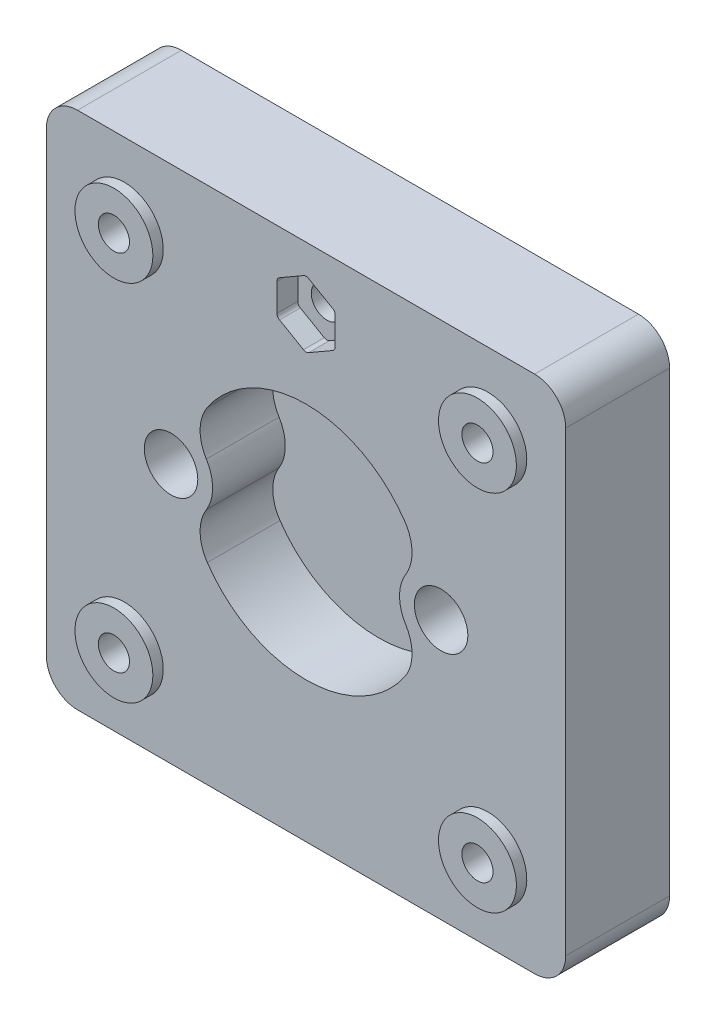
from build123d import *

# Parameters (mm, degrees)
SKETCH1_W               = 50
SKETCH1_H               = 50
BODY_DEPTH              = 10
SKETCH2_R               = 11.5
CUT_VIEW_DEPTH          = 7
FILLETBODY_R            = 3
SKETCH3_R               = 3.75
BOLT_EXTRUDE_DEPTH      = 1
SKETCH4_R               = 1.5
BOLT_DEPTH              = 10
BOLT_DEPTH_BACK         = 16
HEX_2_DEPTH             = 2
SKETCH19_R              = 1.5
HEX_BOLT_DEPTH          = 3
SKETCH6_R               = 4
FIELD1_DEPTH            = 7
FIELD2_R                = 4
SKETCH7_R               = 2.575
PORTS1_DEPTH            = 12
SKETCH10_R              = 1.575
PORTS2_DEPTH            = 12
PORTS2_DEPTH_BACK       = 32
SKETCH11_R              = 20
SKETCH11_R_2            = 15
SEAL1_DEPTH             = 0.5
FLOWFIELD_DEPTH         = 1.5
FLOWFIELD_CHANNEL_DEPTH = 1.5
BODY_MOVE_COPY1_ANGLE   = 90
BODY_MOVE_COPY2_ANGLE   = 180
SKETCH20_R              = 2.575
CUT_EXTRUDE1_DEPTH      = 17
FILLET1_R               = 0.5


with BuildPart() as part:
    # Sketch1 → Body (new body)
    with BuildSketch(Plane(origin=(0, 0, 0), x_dir=(1, 0, 0), z_dir=(0, 1, 0))):
        Rectangle(SKETCH1_W, SKETCH1_H)
    extrude(amount=BODY_DEPTH)

    # Sketch2 → Cut view (cut)
    with BuildSketch(Plane(origin=(0, 10, 0), x_dir=(1, 0, 0), z_dir=(0, 1, 0))):
        Circle(SKETCH2_R)
    extrude(amount=-CUT_VIEW_DEPTH, mode=Mode.SUBTRACT)

    # FilletBody
    filletbody_edges = [part.edges().sort_by_distance(p)[0] for p in [
        (-25, 5, -25),
        (25, 5, -25),
        (25, 5, 25),
        (-25, 5, 25),
    ]]
    fillet(filletbody_edges, radius=FILLETBODY_R)

    # Sketch3 → Bolt extrude (add)
    with BuildSketch(Plane(origin=(0, 10, 0), x_dir=(1, 0, 0), z_dir=(0, 1, 0))):
        with Locations((-17.5, 17.5)):
            Circle(SKETCH3_R)
        with Locations((17.5, 17.5)):
            Circle(SKETCH3_R)
        with Locations((17.5, -17.5)):
            Circle(SKETCH3_R)
        with Locations((-17.5, -17.5)):
            Circle(SKETCH3_R)
    extrude(amount=BOLT_EXTRUDE_DEPTH)

    # Sketch4 → Bolt (cut, two sides)
    with BuildSketch(Plane(origin=(0, 11, 0), x_dir=(1, 0, 0), z_dir=(0, 1, 0))) as bolt_sk:
        with Locations((-17.5, 17.5)):
            Circle(SKETCH4_R)
        with Locations((17.5, 17.5)):
            Circle(SKETCH4_R)
        with Locations((17.5, -17.5)):
            Circle(SKETCH4_R)
        with Locations((-17.5, -17.5)):
            Circle(SKETCH4_R)
    extrude(amount=BOLT_DEPTH, mode=Mode.SUBTRACT)
    extrude(bolt_sk.sketch, amount=-BOLT_DEPTH_BACK, mode=Mode.SUBTRACT)

    # Sketch5 → Hex 2 (cut)
    with BuildSketch(Plane(origin=(0, 10, 0), x_dir=(1, 0, 0), z_dir=(0, 1, 0))):
        Polygon((0, 22.233161507), (-2.8, 20.616580754), (-2.8, 17.383419246), (0, 15.766838493), (2.8, 17.383419246), (2.8, 20.616580754), align=None)
    extrude(amount=-HEX_2_DEPTH, mode=Mode.SUBTRACT)

    # Sketch19 → Hex_bolt (cut)
    with BuildSketch(Plane(origin=(0, 8, 0), x_dir=(1, 0, 0), z_dir=(0, 1, 0))):
        with Locations((0, 19)):
            Circle(SKETCH19_R)
    extrude(amount=-HEX_BOLT_DEPTH, mode=Mode.SUBTRACT)

    # Sketch6 → Field1 (add)
    with BuildSketch(Plane(origin=(0, 10, 0), x_dir=(1, 0, 0), z_dir=(0, 1, 0))):
        with Locations((-13, 0)):
            Circle(SKETCH6_R)
        with Locations((13, 0)):
            Circle(SKETCH6_R)
    extrude(amount=-FIELD1_DEPTH)

    # Field2
    field2_edges = [part.edges().sort_by_distance(p)[0] for p in [
        (-10.971153846, 6.5, 3.447286365),
        (-10.971153846, 6.5, -3.447286365),
        (10.971153846, 6.5, -3.447286365),
        (10.971153846, 6.5, 3.447286365),
    ]]
    fillet(field2_edges, radius=FIELD2_R)

    # Sketch7 → Ports1 (add)
    with BuildSketch(Plane(origin=(0, 10, 0), x_dir=(1, 0, 0), z_dir=(0, 1, 0))):
        with Locations((-13, 0)):
            Circle(SKETCH7_R)
        with Locations((13, 0)):
            Circle(SKETCH7_R)
    extrude(amount=PORTS1_DEPTH)

    # Sketch10 → Ports2 (cut, two sides)
    with BuildSketch(Plane(origin=(0, 22, 0), x_dir=(1, 0, 0), z_dir=(0, 1, 0))) as ports2_sk:
        with Locations((-13, 0)):
            Circle(SKETCH10_R)
        with Locations((13, 0)):
            Circle(SKETCH10_R)
    extrude(amount=PORTS2_DEPTH, mode=Mode.SUBTRACT)
    extrude(ports2_sk.sketch, amount=-PORTS2_DEPTH_BACK, mode=Mode.SUBTRACT)

    # Sketch11 → Seal1 (cut)
    with BuildSketch(Plane.XZ):
        Circle(SKETCH11_R)
        Circle(SKETCH11_R_2, mode=Mode.SUBTRACT)
    extrude(amount=-SEAL1_DEPTH, mode=Mode.SUBTRACT)

    # Sketch15 → FlowField (cut)
    with BuildSketch(Plane.XZ):
        with BuildLine():
            ThreePointArc((13.522961568, 3.623466631), (-1.199537572, 13.948516395), (-13.943052885, 1.261457989))
            ThreePointArc((-13.943052885, 1.261457989), (-12.926234652, 1.573271646), (-11.943052885, 1.167684801))
            ThreePointArc((-11.943052885, 1.167684801), (-0.984919414, 11.95951227), (11.591109915, 3.105828541))
            ThreePointArc((11.591109915, 3.105828541), (12.815854787, 2.39872176), (13.522961568, 3.623466631))
        make_face()
        with BuildLine():
            ThreePointArc((11, 0), (1.910129954, 10.832885283), (-10.336618829, 3.762221577))
            ThreePointArc((-10.336618829, 3.762221577), (-9.738946351, 2.480508812), (-8.457233587, 3.07818129))
            ThreePointArc((-8.457233587, 3.07818129), (1.562833599, 8.863269777), (9, 0))
            Line((9, 0), (11, 0))
        make_face()
        with BuildLine():
            ThreePointArc((7.250462296, 3.380946094), (6.766772771, 2.052020045), (5.437846722, 2.53570957))
            ThreePointArc((5.437846722, 2.53570957), (-1.298637684, 5.857776043), (-6, 0))
            Line((-6, 0), (-8, 0))
            ThreePointArc((-8, 0), (-1.731516912, 7.810368057), (7.250462296, 3.380946094))
        make_face()
        with BuildLine():
            ThreePointArc((5, 0), (1.913417162, 4.619397663), (-3.535533906, 3.535533906))
            ThreePointArc((-3.535533906, 3.535533906), (-3.535533906, 2.121320344), (-2.121320344, 2.121320344))
            ThreePointArc((-2.121320344, 2.121320344), (1.148050297, 2.771638598), (3, 0))
            Line((3, 0), (5, 0))
        make_face()
        with BuildLine():
            ThreePointArc((5, 0), (1.913417162, -4.619397663), (-3.535533906, -3.535533906))
            ThreePointArc((-3.535533906, -3.535533906), (-3.535533906, -2.121320344), (-2.121320344, -2.121320344))
            ThreePointArc((-2.121320344, -2.121320344), (1.148050297, -2.771638598), (3, 0))
            Line((3, 0), (5, 0))
        make_face()
        with BuildLine():
            ThreePointArc((-8, 0), (-1.731516912, -7.810368057), (7.250462296, -3.380946094))
            ThreePointArc((7.250462296, -3.380946094), (6.766772771, -2.052020045), (5.437846722, -2.53570957))
            ThreePointArc((5.437846722, -2.53570957), (-1.298637684, -5.857776043), (-6, 0))
            Line((-6, 0), (-8, 0))
        make_face()
        with BuildLine():
            ThreePointArc((11, 0), (1.910129954, -10.832885283), (-10.336618829, -3.762221577))
            ThreePointArc((-10.336618829, -3.762221577), (-9.738946351, -2.480508812), (-8.457233587, -3.07818129))
            ThreePointArc((-8.457233587, -3.07818129), (1.562833599, -8.863269777), (9, 0))
            Line((9, 0), (11, 0))
        make_face()
        with BuildLine():
            ThreePointArc((-11.943052885, -1.167684801), (-12.926234652, -1.573271646), (-13.943052885, -1.261457989))
            ThreePointArc((-13.943052885, -1.261457989), (-1.199537572, -13.948516395), (13.522961568, -3.623466631))
            ThreePointArc((13.522961568, -3.623466631), (12.815854787, -2.39872176), (11.591109915, -3.105828541))
            ThreePointArc((11.591109915, -3.105828541), (-0.984919414, -11.95951227), (-11.943052885, -1.167684801))
        make_face()
    extrude(amount=-FLOWFIELD_DEPTH, mode=Mode.SUBTRACT)

    # Sketch16 → FlowField_Channel (cut)
    with BuildSketch(Plane.XZ):
        with BuildLine():
            Line((-13, 1), (0, 1))
            ThreePointArc((0, 1), (1, 0), (0, -1))
            Line((0, -1), (-13, -1))
            ThreePointArc((-13, -1), (-14, 0), (-13, 1))
        make_face()
        with BuildLine():
            Line((13, -1), (4.429119544, -1))
            ThreePointArc((4.429119544, -1), (3.429119544, 0), (4.429119544, 1))
            Line((4.429119544, 1), (13, 1))
            ThreePointArc((13, 1), (14, 0), (13, -1))
        make_face()
    extrude(amount=-FLOWFIELD_CHANNEL_DEPTH, mode=Mode.SUBTRACT)


with BuildPart() as body_2:
    # Mirror3: mirrored copy
    add(part.part.mirror(Plane.ZX))


with BuildPart() as body_2_1:
    # Body-Move/Copy1: moved
    add(body_2.part.rotate(Axis((0, -11, 0), (-1, 0, 0)), BODY_MOVE_COPY1_ANGLE))


with BuildPart() as body_2_2:
    # Body-Move/Copy2: moved
    add(body_2_1.part.rotate(Axis((0, -11, 0), (0, 0, 1)), BODY_MOVE_COPY2_ANGLE))

    # Sketch20 → Cut-Extrude1 (cut)
    with BuildSketch(Plane.XY.offset(11)):
        with Locations((-13, -11)):
            Circle(SKETCH20_R)
        with Locations((13, -11)):
            Circle(SKETCH20_R)
    extrude(amount=-CUT_EXTRUDE1_DEPTH, mode=Mode.SUBTRACT)

    # Fillet1
    fillet1_edges = [body_2_2.edges().sort_by_distance(p)[0] for p in [
        (0, 11.233161507, -2),
        (-2.8, 9.616580754, -2),
        (-2.8, 6.383419246, -2),
        (0, 4.766838493, -2),
        (2.8, 6.383419246, -2),
        (2.8, 9.616580754, -2),
    ]]
    fillet(fillet1_edges, radius=FILLET1_R)


solid = body_2_2.part
